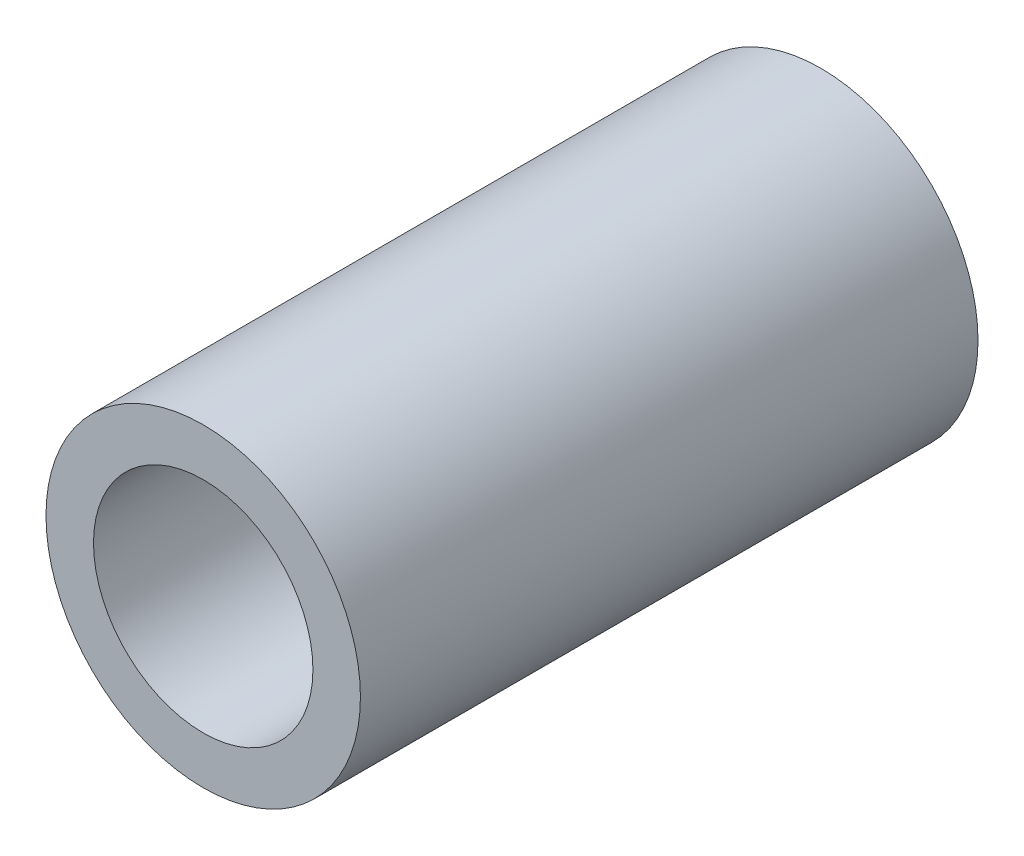
from build123d import *

# Parameters (mm, degrees)
SKETCH1_R           = 10.507348419
SKETCH1_R_2         = 7.332348419
BOSS_EXTRUDE1_DEPTH = 41.275


with BuildPart() as part:
    # Sketch1 → Boss-Extrude1 (new body)
    with BuildSketch(Plane.XY):
        Circle(SKETCH1_R)
        Circle(SKETCH1_R_2, mode=Mode.SUBTRACT)
    extrude(amount=BOSS_EXTRUDE1_DEPTH)


solid = part.part
